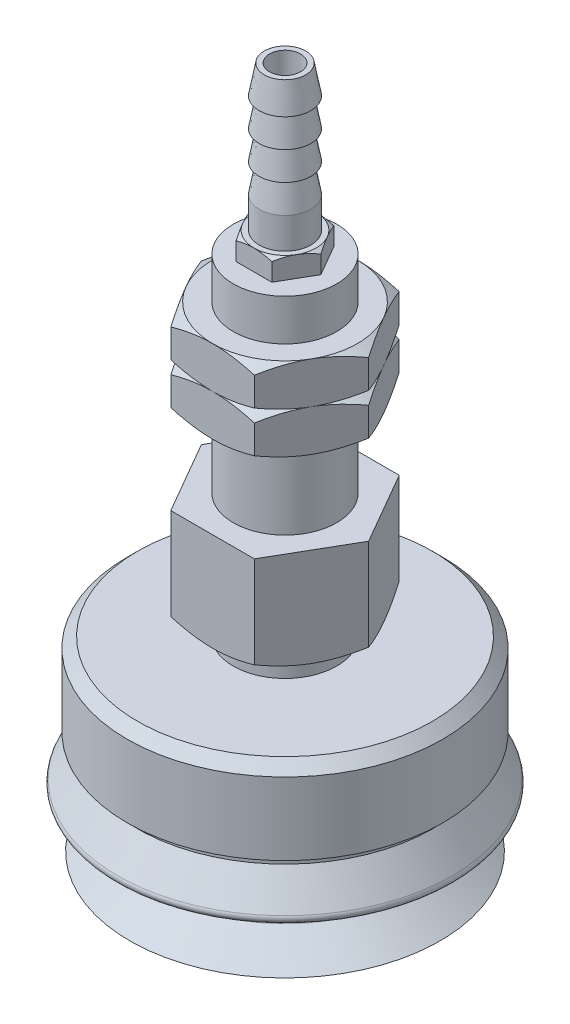
from build123d import *

# Parameters (mm, degrees)
EXTRUDE_1_DEPTH      = 2
SKETCH_4_3_OUTSIDE_W = 57.584
SKETCH_4_3_OUTSIDE_H = 57.584
SKETCH_4_3_OUTSIDE_R = 3
CUT_EXTRUDE_1_DEPTH  = 2
CUT_EXTRUDE_1_TAPER  = 60
EXTRUDE_2_DEPTH      = 4
EXTRUDE_START        = -4
EXTRUDE_3_DEPTH      = 4
SKETCH_5_4_OUTSIDE_W = 64.512
SKETCH_5_4_OUTSIDE_H = 64.512
SKETCH_5_4_OUTSIDE_R = 7
CUT_EXTRUDE_2_DEPTH  = 4
CUT_EXTRUDE_2_TAPER  = 60
CUT_EXTRUDE_START    = -4
SKETCH_5_5_OUTSIDE_W = 78.368
SKETCH_5_5_OUTSIDE_H = 78.368
SKETCH_5_5_OUTSIDE_R = 7
CUT_EXTRUDE_3_DEPTH  = 8
CUT_EXTRUDE_3_TAPER  = 60
SKETCH_5_6_OUTSIDE_W = 64.512
SKETCH_5_6_OUTSIDE_H = 64.512
SKETCH_5_6_OUTSIDE_R = 7
CUT_EXTRUDE_4_DEPTH  = 4
CUT_EXTRUDE_4_TAPER  = 60
CUT_EXTRUDE_START_2  = -8
SKETCH_5_7_OUTSIDE_W = 92.224
SKETCH_5_7_OUTSIDE_H = 92.224
SKETCH_5_7_OUTSIDE_R = 7
CUT_EXTRUDE_5_DEPTH  = 12
CUT_EXTRUDE_5_TAPER  = 60
EXTRUDE_4_DEPTH      = 9.5
CUT_EXTRUDE_START_3  = -9.5
SKETCH_6_5_OUTSIDE_W = 85.296
SKETCH_6_5_OUTSIDE_H = 85.296
SKETCH_6_5_OUTSIDE_R = 7
CUT_EXTRUDE_9_DEPTH  = 10
CUT_EXTRUDE_9_TAPER  = 60
CUT_EXTRUDE_START_4  = -16
SKETCH_8_R           = 1.5
CUT_EXTRUDE_8_DEPTH  = 17
SKETCH_9_W           = 2.15
SKETCH_9_H           = 17.25


with BuildPart() as part:
    # 草图2 → 旋转1 (revolve)
    with BuildSketch(Plane.XY):
        with BuildLine():
            Line((0, 66), (2, 66))
            Line((2, 66), (2.5, 63.25))
            Line((2.5, 63.25), (2, 63.25))
            Line((2, 63.25), (2.5, 60.5))
            Line((2.5, 60.5), (2, 60.5))
            Line((2, 60.5), (2.5, 57.75))
            Line((2.5, 57.75), (2, 57.75))
            Line((2, 57.75), (2.5, 55))
            Line((2.5, 55), (2.5, 52))
            Line((2.5, 52), (3, 52))
            Line((3, 52), (3, 50))
            Line((3, 50), (5, 50))
            Line((5, 50), (5, 46))
            Line((5, 46), (7, 46))
            Line((7, 46), (7, 42))
            Line((7, 42), (7, 38))
            Line((7, 38), (5, 38))
            Line((5, 38), (5, 30))
            Line((5, 30), (7, 30))
            Line((7, 30), (7, 20.5))
            Line((7, 20.5), (5, 20.5))
            Line((5, 20.5), (5, 18))
            Line((5, 18), (14.25, 18))
            Line((14.25, 18), (15.25, 17))
            Line((15.25, 17), (15.25, 10))
            Line((15.25, 10), (14.25, 10))
            Line((14.25, 10), (14.25, 9))
            Line((14.25, 9), (16.196493315, 6.058632324))
            ThreePointArc((16.196493315, 6.058632324), (16.264187236, 5.659797854), (16.014619988, 5.34141508))
            Line((16.014619988, 5.34141508), (11.87145291, 3.134153756))
            ThreePointArc((11.87145291, 3.134153756), (11.607653664, 2.726137813), (11.814942295, 2.286708096))
            Line((11.814942295, 2.286708096), (15, 0))
            Line((15, 0), (14.4, 0))
            Line((14.4, 0), (11.153507909, 2.330814834))
            ThreePointArc((11.153507909, 2.330814834), (10.946219278, 2.770244551), (11.210018525, 3.178260495))
            Line((11.210018525, 3.178260495), (15.510398448, 5.469276547))
            ThreePointArc((15.510398448, 5.469276547), (15.759965696, 5.787659321), (15.692271775, 6.186493791))
            Line((15.692271775, 6.186493791), (14.492157372, 8))
            Line((14.492157372, 8), (0, 8))
            Line((0, 8), (0, 66))
        make_face()
    revolve(axis=Axis((0, 17.903421189, 0), (0, -1, 0)))


with BuildPart() as body_2:
    # 草图4 → 凸台-拉伸1 (new body)
    with BuildSketch(Plane(origin=(0, 52, 0), x_dir=(1, 0, 0), z_dir=(0, 1, 0))):
        Polygon((1.732050808, -3), (3.464101615, 0), (1.732050808, 3), (-1.732050808, 3), (-3.464101615, 0), (-1.732050808, -3), align=None)
    extrude(amount=-EXTRUDE_1_DEPTH)

    # 草图4<3> outside → 切除-拉伸1 (cut)
    with BuildSketch(Plane(origin=(0, 52, 0), x_dir=(1, 0, 0), z_dir=(0, 1, 0))):
        Rectangle(SKETCH_4_3_OUTSIDE_W, SKETCH_4_3_OUTSIDE_H)
        Circle(SKETCH_4_3_OUTSIDE_R, mode=Mode.SUBTRACT)
    extrude(amount=-CUT_EXTRUDE_1_DEPTH, taper=CUT_EXTRUDE_1_TAPER, mode=Mode.SUBTRACT)


with BuildPart() as body_3:
    # 草图5 → 凸台-拉伸2 (new body)
    with BuildSketch(Plane(origin=(0, 46, 0), x_dir=(1, 0, 0), z_dir=(0, 1, 0))):
        Polygon((-4.041451884, 7), (-8.082903769, 0), (-4.041451884, -7), (4.041451884, -7), (8.082903769, 0), (4.041451884, 7), align=None)
    extrude(amount=-EXTRUDE_2_DEPTH)

    # 草图5<4> outside → 切除-拉伸2 (cut)
    with BuildSketch(Plane(origin=(0, 46, 0), x_dir=(1, 0, 0), z_dir=(0, 1, 0))):
        Rectangle(SKETCH_5_4_OUTSIDE_W, SKETCH_5_4_OUTSIDE_H)
        Circle(SKETCH_5_4_OUTSIDE_R, mode=Mode.SUBTRACT)
    extrude(amount=-CUT_EXTRUDE_2_DEPTH, taper=CUT_EXTRUDE_2_TAPER, mode=Mode.SUBTRACT)

    # 草图5<5> outside → 切除-拉伸3 (cut)
    with BuildSketch(Plane(origin=(0, 46, 0), x_dir=(1, 0, 0), z_dir=(0, 1, 0)).offset(CUT_EXTRUDE_START)):
        Rectangle(SKETCH_5_5_OUTSIDE_W, SKETCH_5_5_OUTSIDE_H)
        Circle(SKETCH_5_5_OUTSIDE_R, mode=Mode.SUBTRACT)
    extrude(amount=CUT_EXTRUDE_3_DEPTH, taper=CUT_EXTRUDE_3_TAPER, mode=Mode.SUBTRACT)


with BuildPart() as body_4:
    # 草图5<3> → 凸台-拉伸3 (new body)
    with BuildSketch(Plane(origin=(0, 46, 0), x_dir=(1, 0, 0), z_dir=(0, 1, 0)).offset(EXTRUDE_START)):
        Polygon((-4.041451884, 7), (-8.082903769, 0), (-4.041451884, -7), (4.041451884, -7), (8.082903769, 0), (4.041451884, 7), align=None)
    extrude(amount=-EXTRUDE_3_DEPTH)

    # 草图5<6> outside → 切除-拉伸4 (cut)
    with BuildSketch(Plane(origin=(0, 46, 0), x_dir=(1, 0, 0), z_dir=(0, 1, 0)).offset(CUT_EXTRUDE_START)):
        Rectangle(SKETCH_5_6_OUTSIDE_W, SKETCH_5_6_OUTSIDE_H)
        Circle(SKETCH_5_6_OUTSIDE_R, mode=Mode.SUBTRACT)
    extrude(amount=-CUT_EXTRUDE_4_DEPTH, taper=CUT_EXTRUDE_4_TAPER, mode=Mode.SUBTRACT)

    # 草图5<7> outside → 切除-拉伸5 (cut)
    with BuildSketch(Plane(origin=(0, 46, 0), x_dir=(1, 0, 0), z_dir=(0, 1, 0)).offset(CUT_EXTRUDE_START_2)):
        Rectangle(SKETCH_5_7_OUTSIDE_W, SKETCH_5_7_OUTSIDE_H)
        Circle(SKETCH_5_7_OUTSIDE_R, mode=Mode.SUBTRACT)
    extrude(amount=CUT_EXTRUDE_5_DEPTH, taper=CUT_EXTRUDE_5_TAPER, mode=Mode.SUBTRACT)


with BuildPart() as body_5:
    # 草图6 → 凸台-拉伸4 (new body)
    with BuildSketch(Plane(origin=(0, 30, 0), x_dir=(1, 0, 0), z_dir=(0, 1, 0))):
        Polygon((4.041451884, 7), (-4.041451884, 7), (-8.082903769, 0), (-4.041451884, -7), (4.041451884, -7), (8.082903769, 0), align=None)
    extrude(amount=-EXTRUDE_4_DEPTH)

    # 草图6<5> outside → 切除-拉伸9 (cut)
    with BuildSketch(Plane(origin=(0, 30, 0), x_dir=(1, 0, 0), z_dir=(0, 1, 0)).offset(CUT_EXTRUDE_START_3)):
        Rectangle(SKETCH_6_5_OUTSIDE_W, SKETCH_6_5_OUTSIDE_H)
        Circle(SKETCH_6_5_OUTSIDE_R, mode=Mode.SUBTRACT)
    extrude(amount=CUT_EXTRUDE_9_DEPTH, taper=CUT_EXTRUDE_9_TAPER, mode=Mode.SUBTRACT)


with BuildPart() as part_1:
    add(part.part)

    # Combine 1: union body 3, body 4, body 2, body 5
    add(body_3.part)
    add(body_4.part)
    add(body_2.part)
    add(body_5.part)

    # 草图8 → 切除-拉伸8 (cut, through all)
    with BuildSketch(Plane(origin=(0, 66, 0), x_dir=(1, 0, 0), z_dir=(0, 1, 0)).offset(CUT_EXTRUDE_START_4)):
        Circle(SKETCH_8_R)
    extrude(amount=CUT_EXTRUDE_8_DEPTH, mode=Mode.SUBTRACT)

    # 草图9 → 切除-旋转1 (revolve, cut)
    with BuildSketch(Plane.XY):
        with Locations((1.075, 16.625)):
            Rectangle(SKETCH_9_W, SKETCH_9_H)
    revolve(axis=Axis((0, 84.706300763, 0), (0, -1, 0)), mode=Mode.SUBTRACT)


solid = part_1.part
